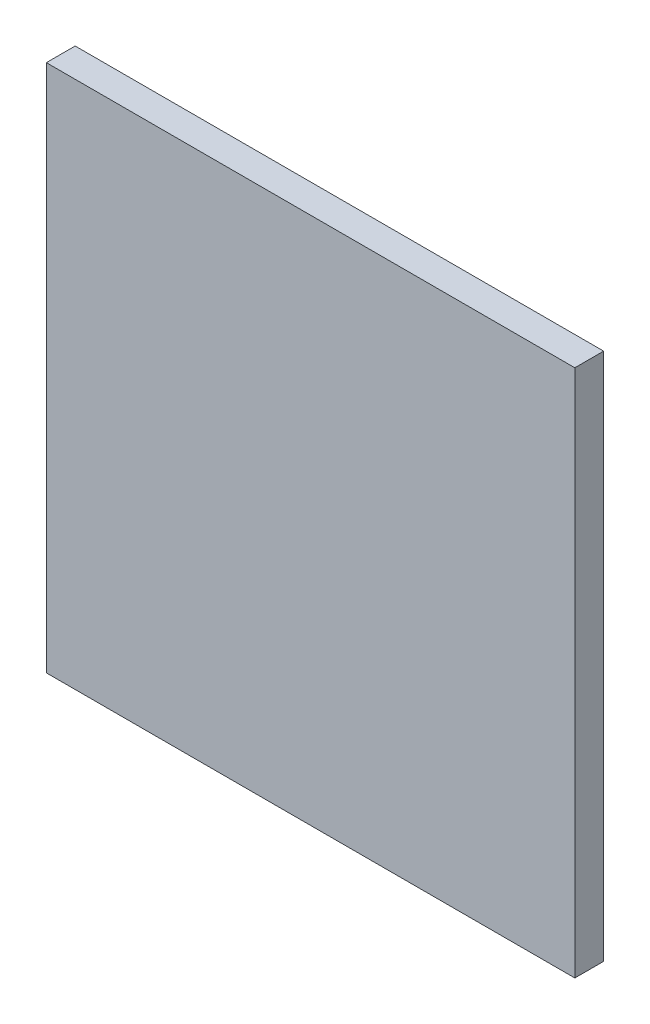
from build123d import *

# Parameters (mm, degrees)
ESQUISSE1_W        = 55
ESQUISSE1_H        = 55
BOSS_EXTRU_1_DEPTH = 3


with BuildPart() as part:
    # Esquisse1 → Boss.-Extru.1 (new body)
    with BuildSketch(Plane.XY):
        Rectangle(ESQUISSE1_W, ESQUISSE1_H)
    extrude(amount=BOSS_EXTRU_1_DEPTH)


solid = part.part
